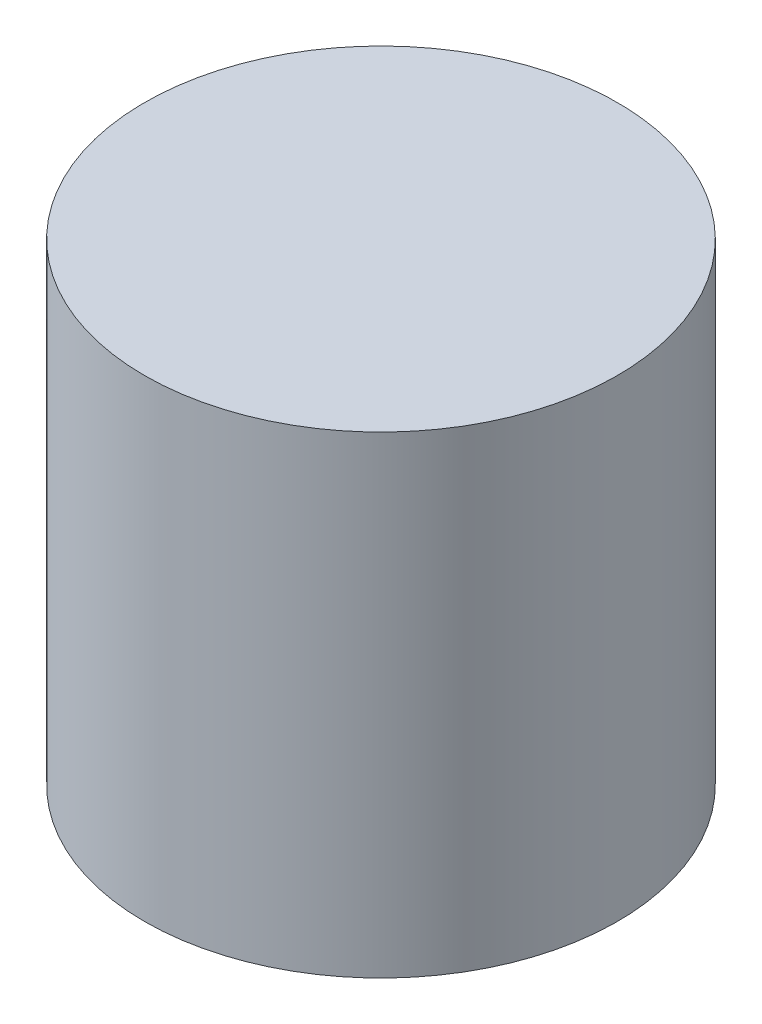
from build123d import *

# Parameters (mm, degrees)
SKETCH2_R           = 63.5
BOSS_EXTRUDE1_DEPTH = 127


with BuildPart() as part:
    # Sketch2 → Boss-Extrude1 (new body)
    with BuildSketch(Plane(origin=(0, 0, 0), x_dir=(1, 0, 0), z_dir=(0, 1, 0))):
        with Locations((-57.470170572, 30.863610122)):
            Circle(SKETCH2_R)
    extrude(amount=BOSS_EXTRUDE1_DEPTH)


solid = part.part
